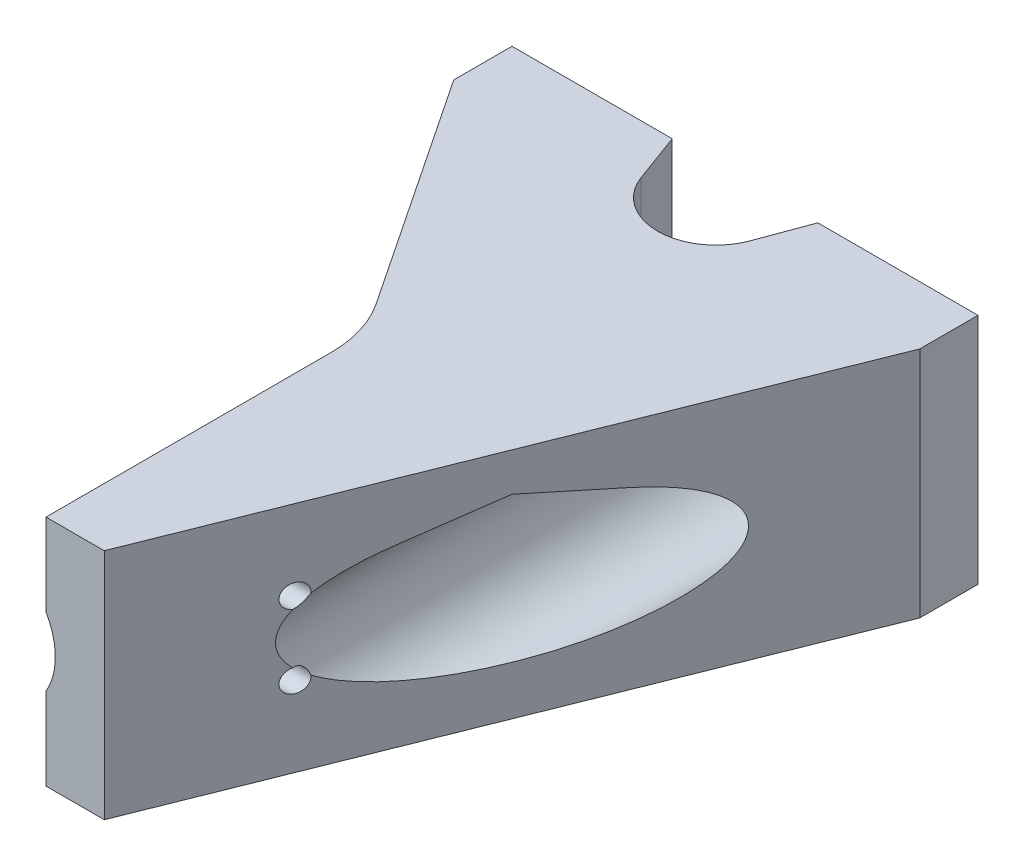
from build123d import *

# Parameters (mm, degrees)
BOSS_EXTRUDE1_DEPTH   = 12.7
CUT_EXTRUDE1_DEPTH    = 10.525
CUT_EXTRUDE2_DEPTH    = 61.3250001
LPATTERN1_COUNT       = 2
LPATTERN1_PITCH       = 25.4
M3X0_5_TAPPED_HOLE1_D = 2.5


with BuildPart() as part:
    # Sketch1 → Boss-Extrude1 (new body, symmetric)
    with BuildSketch(Plane(origin=(0, 0, 0), x_dir=(1, 0, 0), z_dir=(0, 1, 0))):
        with BuildLine():
            Line((0, 0), (17.4625, 0))
            Line((17.4625, 0), (19.441706855, -5.370732862))
            ThreePointArc((19.441706855, -5.370732862), (25.4, -9.525), (31.358293145, -5.370732862))
            Line((31.358293145, -5.370732862), (33.3375, 0))
            Line((33.3375, 0), (50.8, 0))
            Line((50.8, 0), (50.8, -6.35))
            Line((50.8, -6.35), (25.4, -69.85))
            Line((25.4, -69.85), (19.05, -69.85))
            Line((19.05, -69.85), (19.05, -38.770250599))
            ThreePointArc((19.05, -38.770250599), (18.505068736, -35.089991911), (16.917038738, -31.725558107))
            Line((16.917038738, -31.725558107), (0, -6.35))
            Line((0, -6.35), (0, 0))
        make_face()
    extrude(amount=BOSS_EXTRUDE1_DEPTH, both=True)

    # Sketch2 → Cut-Revolve1 (revolve, cut)
    with BuildSketch(Plane(origin=(0, 0, 0), x_dir=(1, 0, 0), z_dir=(0, 1, 0))):
        Polygon((12.7, 0), (12.7, -120.015), (5.334, -120.015), (5.334, -9.525), (10.1473, -9.525), (10.1473, 0), align=None)
    cut_revolve1 = revolve(axis=Axis((12.7, 0, 0), (0, 0, -1)), mode=Mode.SUBTRACT)

    # Sketch6 → Cut-Extrude1 (cut, through all)
    with BuildSketch(Plane.XY.offset(9.525)):
        with BuildLine():
            Line((11.42365, 2.210703048), (12.7, 2.947604064))
            Line((12.7, 2.947604064), (13.97635, 2.210703048))
            ThreePointArc((13.97635, 2.210703048), (12.7, 2.5527), (11.42365, 2.210703048))
        make_face()
    cut_extrude1 = extrude(amount=-CUT_EXTRUDE1_DEPTH, mode=Mode.SUBTRACT)

    # Sketch7 → Cut-Extrude2 (cut, through all)
    with BuildSketch(Plane.XY.offset(9.525)):
        with BuildLine():
            Line((9.017, 6.379143124), (12.7, 8.505524166))
            Line((12.7, 8.505524166), (16.383, 6.379143124))
            ThreePointArc((16.383, 6.379143124), (12.7, 7.366), (9.017, 6.379143124))
        make_face()
    cut_extrude2 = extrude(amount=CUT_EXTRUDE2_DEPTH, mode=Mode.SUBTRACT)

    # LPattern1: Cut-Revolve1, Cut-Extrude1, Cut-Extrude2 ×2
    with Locations(*[(i * LPATTERN1_PITCH, 0, 0) for i in range(1, LPATTERN1_COUNT)]):
        add(cut_revolve1, mode=Mode.SUBTRACT)
        add(cut_extrude1, mode=Mode.SUBTRACT)
        add(cut_extrude2, mode=Mode.SUBTRACT)

    # M3x0.5 Tapped Hole1 (through all)
    with Locations(Plane.ZY.offset(-19.05)):
        with Locations((55, 4), (55, -4)):
            Hole(M3X0_5_TAPPED_HOLE1_D / 2)


solid = part.part
